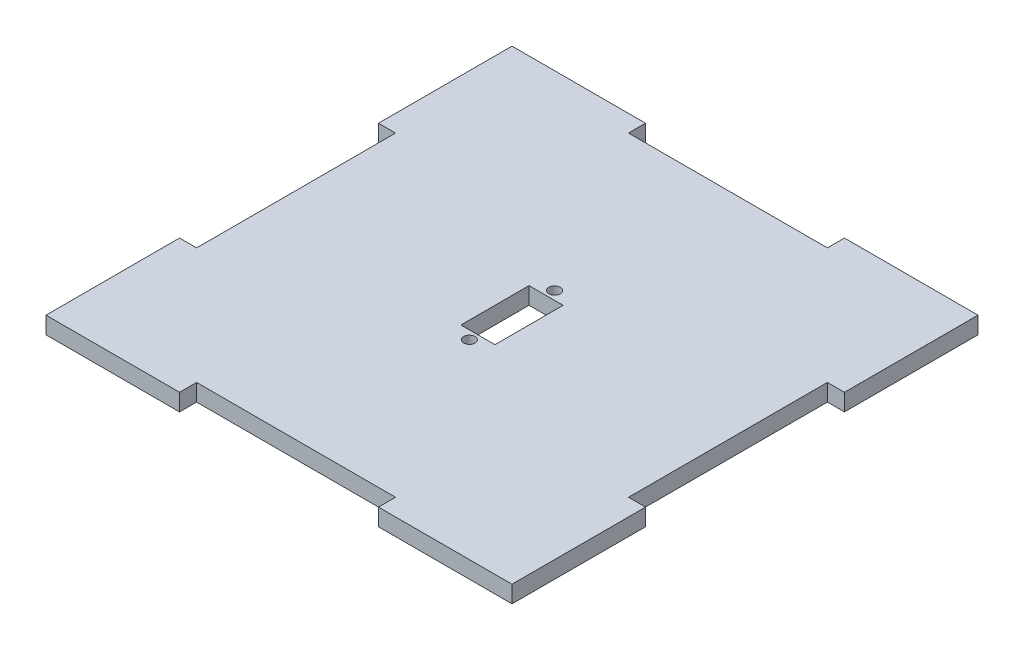
from build123d import *

# Parameters (mm, degrees)
BOSS_EXTRUDE1_DEPTH = 3
SKETCH2_R           = 1
SKETCH2_W           = 6
SKETCH2_H           = 12
CUT_EXTRUDE1_DEPTH  = 3


with BuildPart() as part:
    # Sketch1 → Boss-Extrude1 (new body)
    with BuildSketch(Plane(origin=(0, 0, 0), x_dir=(1, 0, 0), z_dir=(0, 1, 0))):
        Polygon((-41, -41), (-17.5, -41), (-17.5, -38), (17.5, -38), (17.5, -41), (41, -41), (41, -17.5), (38, -17.5), (38, 17.5), (41, 17.5), (41, 41), (17.5, 41), (17.5, 38), (-17.5, 38), (-17.5, 41), (-41, 41), (-41, 17.5), (-38, 17.5), (-38, -17.5), (-41, -17.5), align=None)
    extrude(amount=BOSS_EXTRUDE1_DEPTH)

    # Sketch2 → Cut-Extrude1 (cut)
    with BuildSketch(Plane(origin=(0, 3, 0), x_dir=(1, 0, 0), z_dir=(0, 1, 0))):
        with Locations((0, 7.5)):
            Circle(SKETCH2_R)
        with Locations((0, -7.5)):
            Circle(SKETCH2_R)
        Rectangle(SKETCH2_W, SKETCH2_H)
    extrude(amount=-CUT_EXTRUDE1_DEPTH, mode=Mode.SUBTRACT)


solid = part.part
